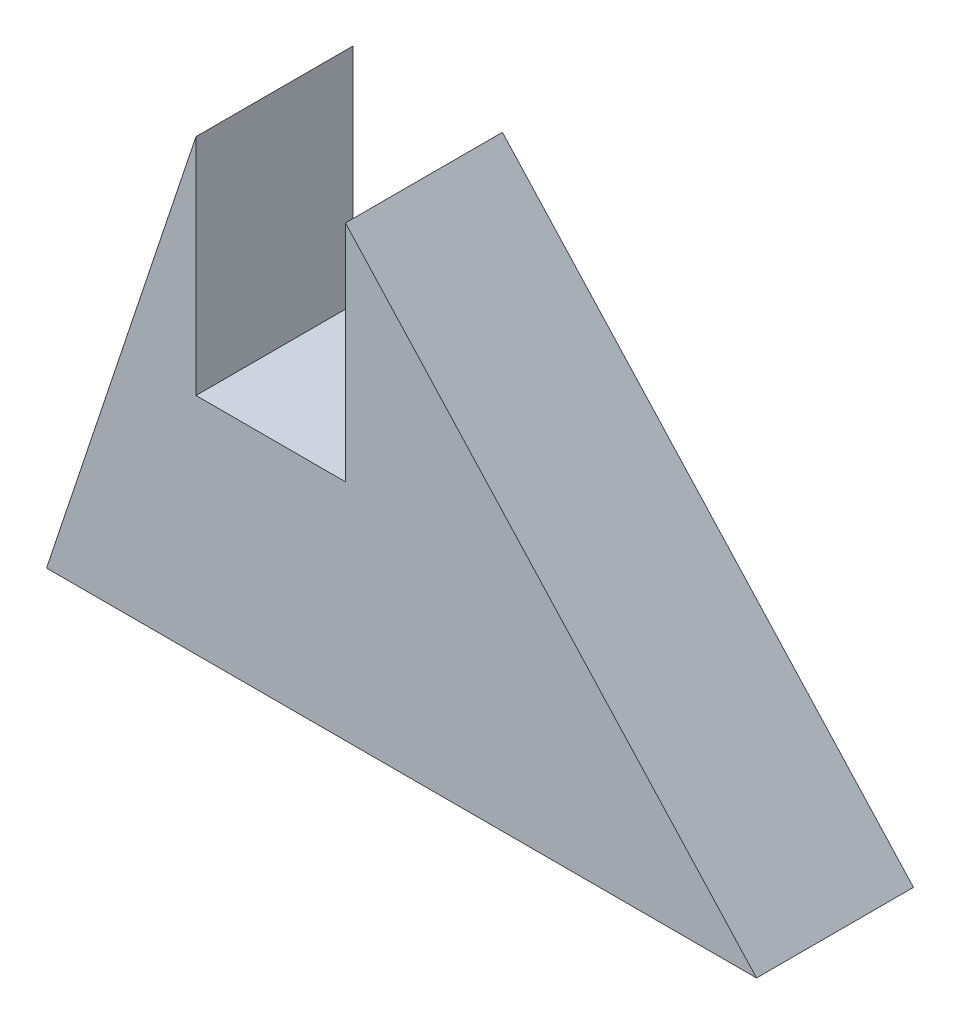
from build123d import *

# Parameters (mm, degrees)
BOSS_EXTRUDE1_DEPTH = 21
SKETCH2_W           = 20
SKETCH2_H           = 30
CUT_EXTRUDE1_DEPTH  = 21


with BuildPart() as part:
    # Sketch1 → Boss-Extrude1 (new body)
    with BuildSketch(Plane.XY):
        Polygon((0, 0), (20, 60), (40, 60), (95, 0), (40, 0), (20, 0), align=None)
    extrude(amount=BOSS_EXTRUDE1_DEPTH)

    # Sketch2 → Cut-Extrude1 (cut)
    with BuildSketch(Plane.XY.offset(21)):
        with Locations((30, 45)):
            Rectangle(SKETCH2_W, SKETCH2_H)
    extrude(amount=-CUT_EXTRUDE1_DEPTH, mode=Mode.SUBTRACT)


solid = part.part
